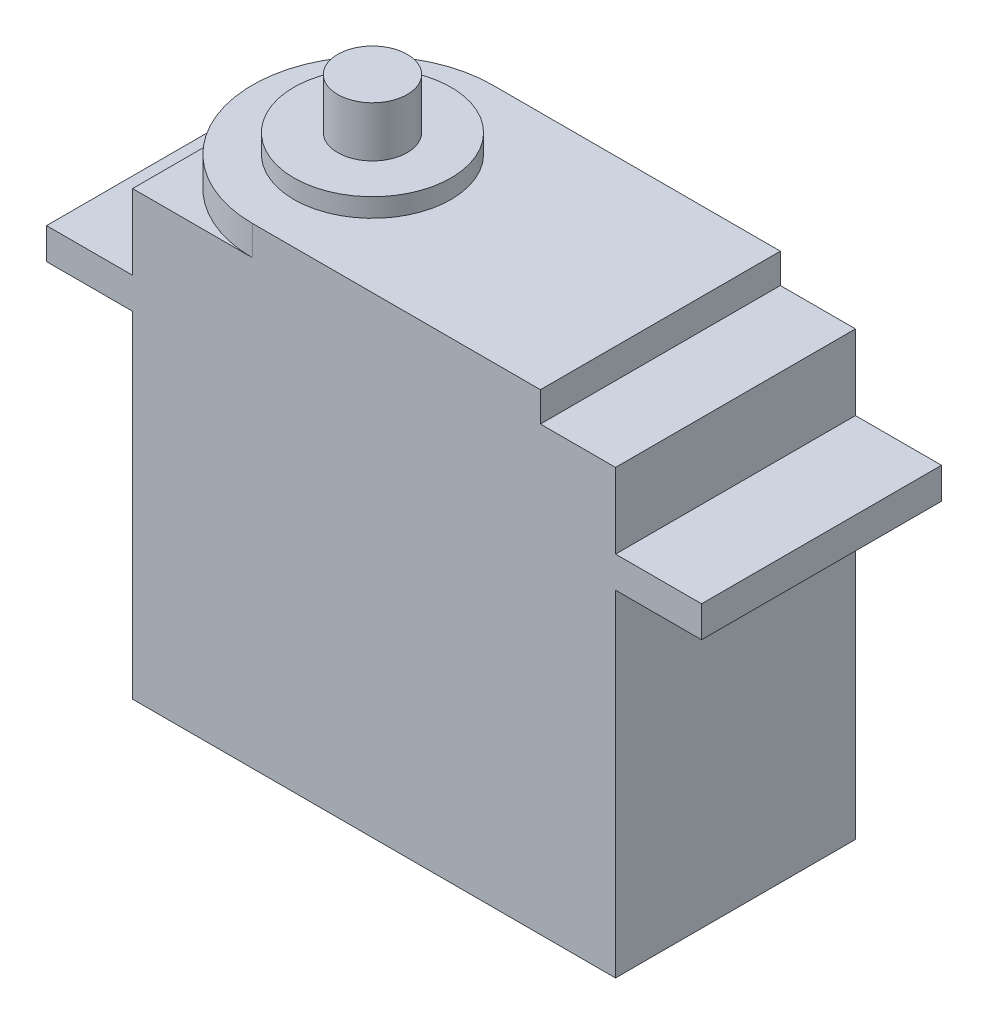
from build123d import *

# Parameters (mm, degrees)
SKETCH1_W           = 40.26
SKETCH1_H           = 20
BOSS_EXTRUDE1_DEPTH = 36.86
SKETCH2_W           = 20
SKETCH2_H           = 2.6
BOSS_EXTRUDE2_DEPTH = 7.17
SKETCH3_W           = 20
SKETCH3_H           = 2.6
BOSS_EXTRUDE3_DEPTH = 7.17
SKETCH4_R           = 10
BOSS_EXTRUDE4_DEPTH = 2.48
SKETCH5_R           = 6.55
BOSS_EXTRUDE5_DEPTH = 1.56
SKETCH6_R           = 2.9
BOSS_EXTRUDE6_DEPTH = 4.2


with BuildPart() as part:
    # Sketch1 → Boss-Extrude1 (new body)
    with BuildSketch(Plane(origin=(0, 0, 0), x_dir=(1, 0, 0), z_dir=(0, 1, 0))):
        Rectangle(SKETCH1_W, SKETCH1_H)
    extrude(amount=BOSS_EXTRUDE1_DEPTH)

    # Sketch2 → Boss-Extrude2 (add)
    with BuildSketch(Plane(origin=(20.13, 0, 0), x_dir=(0, 0, -1), z_dir=(1, 0, 0))):
        with Locations((0, 29.3)):
            Rectangle(SKETCH2_W, SKETCH2_H)
    extrude(amount=BOSS_EXTRUDE2_DEPTH)

    # Sketch3 → Boss-Extrude3 (add)
    with BuildSketch(Plane.ZY.offset(20.13)):
        with Locations((0, 29.3)):
            Rectangle(SKETCH3_W, SKETCH3_H)
    extrude(amount=BOSS_EXTRUDE3_DEPTH)

    # Sketch4 → Boss-Extrude4 (add)
    with BuildSketch(Plane(origin=(0, 36.86, 0), x_dir=(1, 0, 0), z_dir=(0, 1, 0))):
        with Locations((-10.13, 0)):
            Circle(SKETCH4_R)
        with BuildLine():
            Line((13.87, 10), (-10.13, 10))
            ThreePointArc((-10.13, 10), (-3.058932188, 7.071067812), (-0.13, 0))
            ThreePointArc((-0.13, 0), (-3.058932188, -7.071067812), (-10.13, -10))
            Line((-10.13, -10), (13.87, -10))
            Line((13.87, -10), (13.87, 10))
        make_face()
    extrude(amount=BOSS_EXTRUDE4_DEPTH)

    # Sketch5 → Boss-Extrude5 (add)
    with BuildSketch(Plane(origin=(0, 39.34, 0), x_dir=(1, 0, 0), z_dir=(0, 1, 0))):
        with Locations((-10.13, 0)):
            Circle(SKETCH5_R)
    extrude(amount=BOSS_EXTRUDE5_DEPTH)

    # Sketch6 → Boss-Extrude6 (add)
    with BuildSketch(Plane(origin=(0, 40.9, 0), x_dir=(1, 0, 0), z_dir=(0, 1, 0))):
        with Locations((-10.13, 0)):
            Circle(SKETCH6_R)
    extrude(amount=BOSS_EXTRUDE6_DEPTH)


solid = part.part
